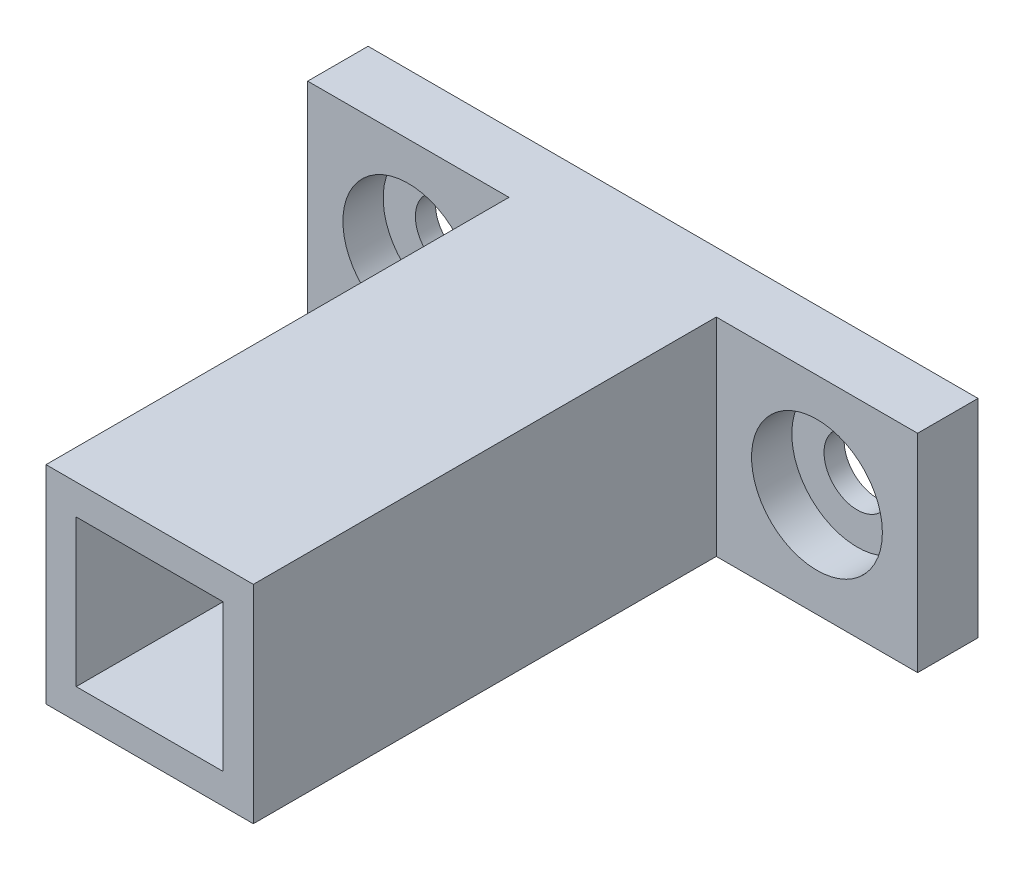
from build123d import *

# Parameters (mm, degrees)
CROQUIS1_W              = 10.3
CROQUIS1_H              = 10.3
CROQUIS1_W_2            = 7.3
CROQUIS1_H_2            = 7.3
SALIENTE_EXTRUIR1_DEPTH = 26
CROQUIS2_W              = 10
CROQUIS2_H              = 10.3
CROQUIS2_R              = 1.65
SALIENTE_EXTRUIR2_DEPTH = 3
CROQUIS3_R              = 3.25
CORTAR_EXTRUIR1_DEPTH   = 2


with BuildPart() as part:
    # Croquis1 → Saliente-Extruir1 (new body)
    with BuildSketch(Plane.XY):
        with Locations((-56.473903104, 61.98267988)):
            Rectangle(CROQUIS1_W, CROQUIS1_H)
        with Locations((-56.473903104, 61.98267988)):
            Rectangle(CROQUIS1_W_2, CROQUIS1_H_2, mode=Mode.SUBTRACT)
    extrude(amount=SALIENTE_EXTRUIR1_DEPTH)

    # Croquis2 → Saliente-Extruir2 (add)
    with BuildSketch(Plane.XY):
        with Locations((-46.323903104, 61.98267988)):
            Rectangle(CROQUIS2_W, CROQUIS2_H)
        with Locations((-46.323903104, 61.98267988)):
            Circle(CROQUIS2_R, mode=Mode.SUBTRACT)
        with Locations((-66.623903104, 61.98267988)):
            Rectangle(CROQUIS2_W, CROQUIS2_H)
        with Locations((-66.623903104, 61.98267988)):
            Circle(CROQUIS2_R, mode=Mode.SUBTRACT)
    extrude(amount=SALIENTE_EXTRUIR2_DEPTH)

    # Croquis3 → Cortar-Extruir1 (cut)
    with BuildSketch(Plane.XY.offset(3)):
        with Locations((-66.623903104, 61.98267988)):
            Circle(CROQUIS3_R)
        with Locations((-46.323903104, 61.98267988)):
            Circle(CROQUIS3_R)
    extrude(amount=-CORTAR_EXTRUIR1_DEPTH, mode=Mode.SUBTRACT)


solid = part.part
